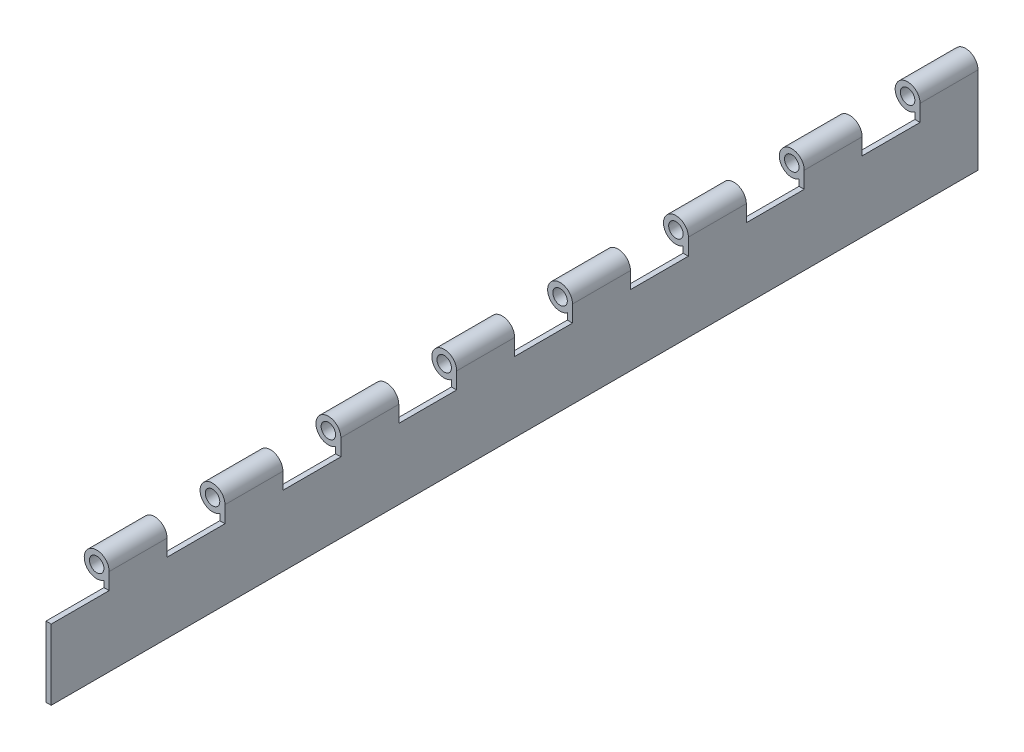
from build123d import *

# Parameters (mm, degrees)
SKETCH1_R           = 3.175
BOSS_EXTRUDE1_DEPTH = 406.4
SKETCH2_W           = 25.4
SKETCH2_H           = 12.7
CUT_EXTRUDE1_DEPTH  = 11.922
LPATTERN1_COUNT     = 8
LPATTERN1_PITCH     = 50.8


with BuildPart() as part:
    # Sketch1 → Boss-Extrude1 (new body)
    with BuildSketch(Plane.XY):
        with BuildLine():
            Line((5.461, 0), (5.461, -38.1))
            Line((5.461, -38.1), (3.175, -38.1))
            Line((3.175, -38.1), (3.175, -4.443185344))
            ThreePointArc((3.175, -4.443185344), (-4.855985791, 2.498384078), (5.461, 0))
        make_face()
        Circle(SKETCH1_R, mode=Mode.SUBTRACT)
    extrude(amount=BOSS_EXTRUDE1_DEPTH)

    # Sketch2 → Cut-Extrude1 (cut, through all)
    with BuildSketch(Plane(origin=(5.461, 0, 0), x_dir=(0, 0, -1), z_dir=(1, 0, 0))):
        with Locations((-393.7, -0.889)):
            Rectangle(SKETCH2_W, SKETCH2_H)
    cut_extrude1 = extrude(amount=-CUT_EXTRUDE1_DEPTH, mode=Mode.SUBTRACT)

    # LPattern1: Cut-Extrude1 ×8
    with Locations(*[(0, 0, -i * LPATTERN1_PITCH) for i in range(1, LPATTERN1_COUNT)]):
        add(cut_extrude1, mode=Mode.SUBTRACT)


solid = part.part
